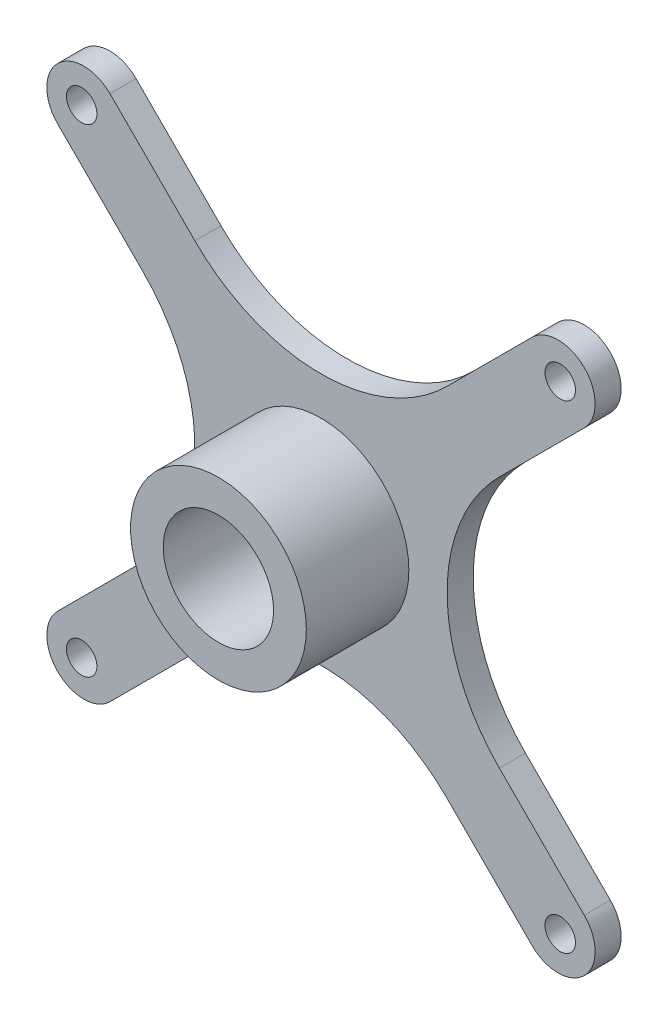
from build123d import *

# Parameters (mm, degrees)
SKETCH1_R           = 3.765
BOSS_EXTRUDE1_DEPTH = 1.78
SKETCH2_R           = 6
SKETCH2_R_2         = 3.765
BOSS_EXTRUDE2_DEPTH = 7


with BuildPart() as part:
    # Sketch1 → Boss-Extrude1 (new body)
    with BuildSketch(Plane.XY):
        with BuildLine():
            Line((-17.975, 14.404110755), (-12.177560595, 8.60667135))
            ThreePointArc((-12.177560595, 8.60667135), (-8.612560595, 0), (-12.177560595, -8.60667135))
            Line((-12.177560595, -8.60667135), (-17.975, -14.404110755))
            ThreePointArc((-17.975, -14.404110755), (-18.714555378, -16.189555378), (-17.975, -17.975))
            ThreePointArc((-17.975, -17.975), (-16.189555378, -18.714555378), (-14.404110755, -17.975))
            Line((-14.404110755, -17.975), (-8.60667135, -12.177560595))
            ThreePointArc((-8.60667135, -12.177560595), (0, -8.612560595), (8.60667135, -12.177560595))
            Line((8.60667135, -12.177560595), (14.404110755, -17.975))
            ThreePointArc((14.404110755, -17.975), (16.189555378, -18.714555378), (17.975, -17.975))
            ThreePointArc((17.975, -17.975), (18.714555378, -16.189555378), (17.975, -14.404110755))
            Line((17.975, -14.404110755), (12.177560595, -8.60667135))
            ThreePointArc((12.177560595, -8.60667135), (8.612560595, 0), (12.177560595, 8.60667135))
            Line((12.177560595, 8.60667135), (17.975, 14.404110755))
            ThreePointArc((17.975, 14.404110755), (18.714555378, 16.189555378), (17.975, 17.975))
            ThreePointArc((17.975, 17.975), (16.189555378, 18.714555378), (14.404110755, 17.975))
            Line((14.404110755, 17.975), (8.60667135, 12.177560595))
            ThreePointArc((8.60667135, 12.177560595), (0, 8.612560595), (-8.60667135, 12.177560595))
            Line((-8.60667135, 12.177560595), (-14.404110755, 17.975))
            ThreePointArc((-14.404110755, 17.975), (-16.189555378, 18.714555378), (-17.975, 17.975))
            ThreePointArc((-17.975, 17.975), (-18.714555378, 16.189555378), (-17.975, 14.404110755))
        make_face()
        Circle(SKETCH1_R, mode=Mode.SUBTRACT)
        with BuildLine():
            ThreePointArc((-17.07, 17.07), (-17.07, 15.599217895), (-15.599217895, 15.599217895))
            ThreePointArc((-15.599217895, 15.599217895), (-15.599217895, 17.07), (-17.07, 17.07))
        make_face(mode=Mode.SUBTRACT)
        with BuildLine():
            ThreePointArc((-15.599217895, -15.599217895), (-17.07, -15.599217895), (-17.07, -17.07))
            ThreePointArc((-17.07, -17.07), (-15.599217895, -17.07), (-15.599217895, -15.599217895))
        make_face(mode=Mode.SUBTRACT)
        with BuildLine():
            ThreePointArc((17.07, 17.07), (15.599217895, 17.07), (15.599217895, 15.599217895))
            ThreePointArc((15.599217895, 15.599217895), (17.07, 15.599217895), (17.07, 17.07))
        make_face(mode=Mode.SUBTRACT)
        with BuildLine():
            ThreePointArc((17.07, -17.07), (17.07, -15.599217895), (15.599217895, -15.599217895))
            ThreePointArc((15.599217895, -15.599217895), (15.599217895, -17.07), (17.07, -17.07))
        make_face(mode=Mode.SUBTRACT)
    extrude(amount=BOSS_EXTRUDE1_DEPTH)

    # Sketch2 → Boss-Extrude2 (add)
    with BuildSketch(Plane.XY.offset(1.78)):
        Circle(SKETCH2_R)
        Circle(SKETCH2_R_2, mode=Mode.SUBTRACT)
    extrude(amount=BOSS_EXTRUDE2_DEPTH)


solid = part.part
